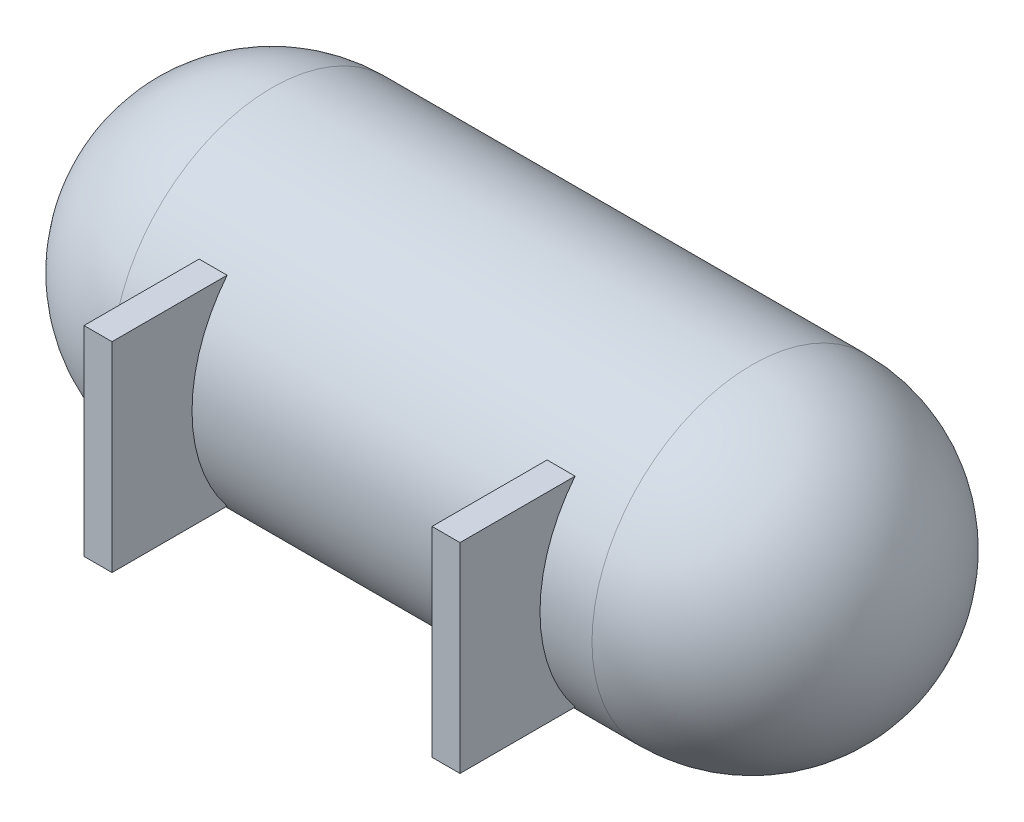
from build123d import *

# Parameters (mm, degrees)
P_IDAT_VYSUNUT_M2_REACH = 502
SKICA2_W                = 35
SKICA2_H                = 250


with BuildPart() as part:
    # Skica1 → Rotovat1 (revolve)
    with BuildSketch(Plane.XY):
        with BuildLine():
            Line((200, 200), (800, 200))
            ThreePointArc((800, 200), (941.421356237, 141.421356237), (1000, 0))
            Line((1000, 0), (990, 0))
            ThreePointArc((990, 0), (934.350288425, 134.350288425), (800, 190))
            Line((800, 190), (200, 190))
            ThreePointArc((200, 190), (65.649711575, 134.350288425), (10, 0))
            Line((10, 0), (0, 0))
            ThreePointArc((0, 0), (58.578643763, 141.421356237), (200, 200))
        make_face()
    revolve(axis=Axis((0, 0, 0), (1, 0, 0)))

    # Skica2 → Přidat vysunutím2 (add, up to next)
    with BuildSketch(Plane.XY.offset(300), mode=Mode.PRIVATE) as p_idat_vysunut_m2_sk1:
        with Locations((717.5, 0)):
            Rectangle(SKICA2_W, SKICA2_H)
    p_idat_vysunut_m2_tool1 = extrude(p_idat_vysunut_m2_sk1.sketch, amount=-P_IDAT_VYSUNUT_M2_REACH, mode=Mode.PRIVATE) - part.part
    add(p_idat_vysunut_m2_tool1.solids().sort_by_distance((717.5, 0, 300))[0])
    # Skica2 → Přidat vysunutím2 (add, up to next)
    with BuildSketch(Plane.XY.offset(300), mode=Mode.PRIVATE) as p_idat_vysunut_m2_sk2:
        with Locations((282.5, 0)):
            Rectangle(SKICA2_W, SKICA2_H)
    p_idat_vysunut_m2_tool2 = extrude(p_idat_vysunut_m2_sk2.sketch, amount=-P_IDAT_VYSUNUT_M2_REACH, mode=Mode.PRIVATE) - part.part
    add(p_idat_vysunut_m2_tool2.solids().sort_by_distance((282.5, 0, 300))[0])


solid = part.part
